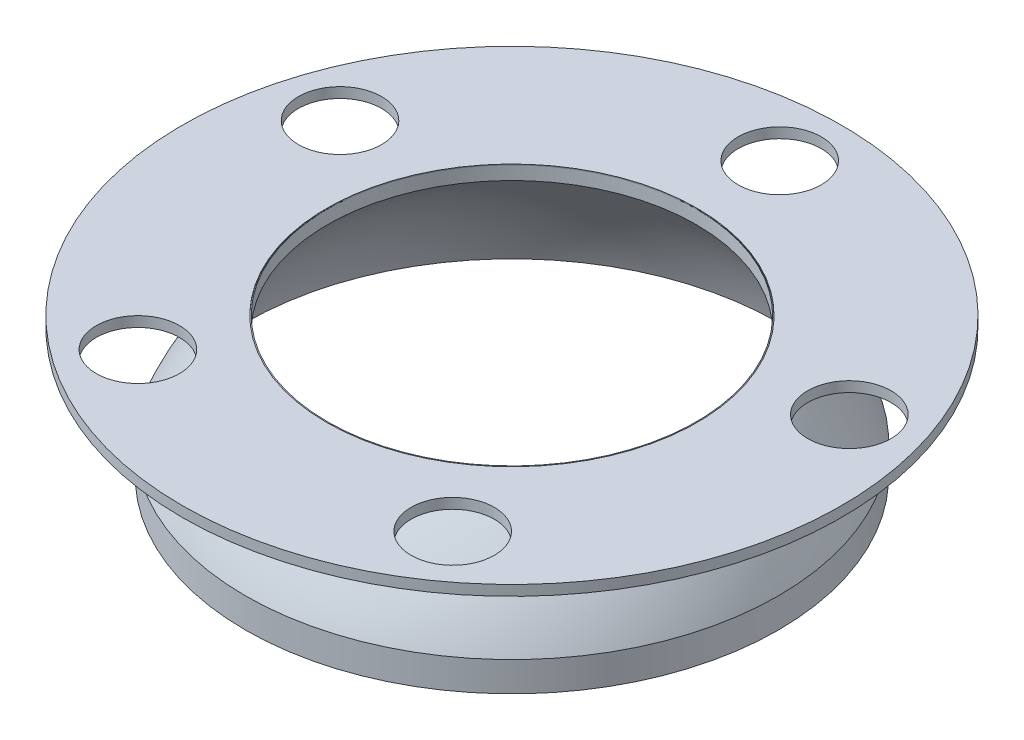
from build123d import *

# Parameters (mm, degrees)
SKETCH2_R           = 101.6
SKETCH2_R_2         = 57.15
SKETCH2_R_3         = 12.827
BOSS_EXTRUDE1_DEPTH = 3.175


with BuildPart() as part:
    # Sketch1 → Revolve1 (revolve)
    with BuildSketch(Plane(origin=(0, -65.689447684, 0), x_dir=(0, 0, -1), z_dir=(1, 0, 0))):
        with BuildLine():
            Line((-82.125635067, 25.890387499), (-82.125635067, 35.031290154))
            ThreePointArc((-82.125635067, 35.031290154), (-71.509443379, 53.46223651), (-56.835063666, 68.859180674))
            Line((-56.835063666, 68.859180674), (-56.835063666, 64.689316259))
            ThreePointArc((-56.835063666, 64.689316259), (-72.137772119, 47.022057948), (-82.125635067, 25.890387499))
        make_face()
    revolve(axis=Axis((0, -65.689447684, 0), (0, 1, 0)))


with BuildPart() as body_2:
    # Sketch2 → Boss-Extrude1 (new body)
    with BuildSketch(Plane(origin=(0, 0, 0), x_dir=(1, 0, 0), z_dir=(0, 1, 0))):
        Circle(SKETCH2_R)
        Circle(SKETCH2_R_2, mode=Mode.SUBTRACT)
        with Locations((-78.50971542, 25.509352886)):
            Circle(SKETCH2_R_3, mode=Mode.SUBTRACT)
        with Locations((-48.521672577, -66.784352886)):
            Circle(SKETCH2_R_3, mode=Mode.SUBTRACT)
        with Locations((48.521672577, -66.784352886)):
            Circle(SKETCH2_R_3, mode=Mode.SUBTRACT)
        with Locations((78.50971542, 25.509352886)):
            Circle(SKETCH2_R_3, mode=Mode.SUBTRACT)
        with Locations((0, 82.55)):
            Circle(SKETCH2_R_3, mode=Mode.SUBTRACT)
    extrude(amount=BOSS_EXTRUDE1_DEPTH)


solid = Compound([part.part, body_2.part])
